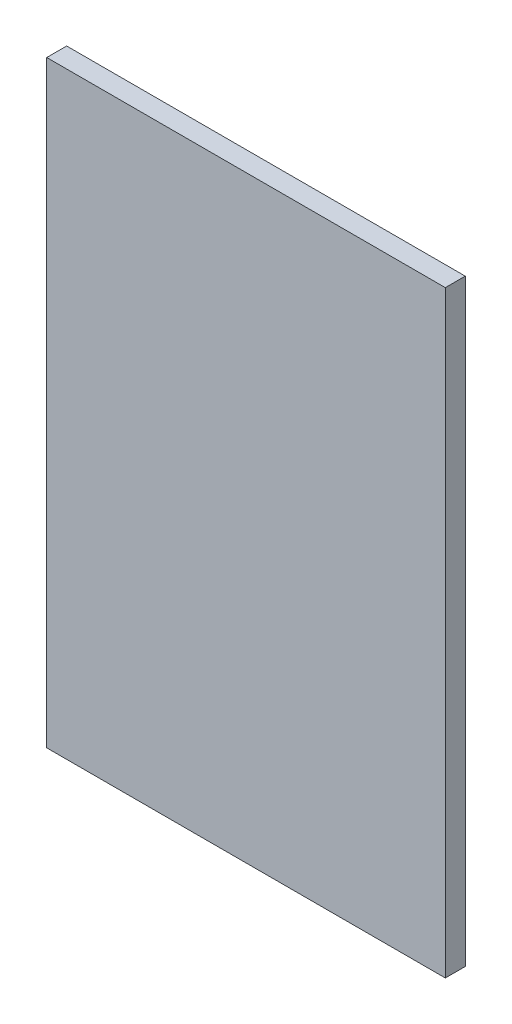
from build123d import *

# Parameters (mm, degrees)
SKETCH1_W           = 200
SKETCH1_H           = 300
BOSS_EXTRUDE1_DEPTH = 10


with BuildPart() as part:
    # Sketch1 → Boss-Extrude1 (new body)
    with BuildSketch(Plane.XY):
        with Locations((100, 150)):
            Rectangle(SKETCH1_W, SKETCH1_H)
    extrude(amount=BOSS_EXTRUDE1_DEPTH)


solid = part.part
